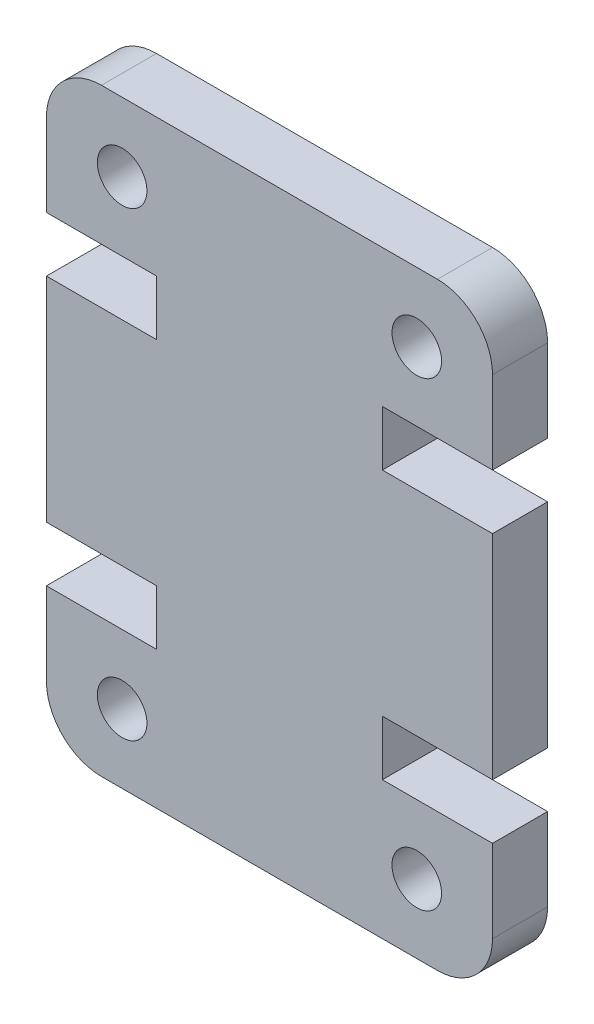
from build123d import *

# Parameters (mm, degrees)
SKETCH1_R           = 0.9
BOSS_EXTRUDE1_DEPTH = 4
SKETCH2_W           = 16.2
SKETCH2_H           = 21.74
CUT_EXTRUDE1_DEPTH  = 2


with BuildPart() as part:
    # Sketch1 → Boss-Extrude1 (new body)
    with BuildSketch(Plane.XY):
        with BuildLine():
            Line((0, 14.74), (0, 7))
            Line((0, 7), (4, 7))
            Line((4, 7), (4, 5))
            Line((4, 5), (0, 5))
            Line((0, 5), (0, 2))
            ThreePointArc((0, 2), (0.585786438, 0.585786438), (2, 0))
            Line((2, 0), (14.2, 0))
            ThreePointArc((14.2, 0), (15.614213562, 0.585786438), (16.2, 2))
            Line((16.2, 2), (16.2, 5))
            Line((16.2, 5), (12.2, 5))
            Line((12.2, 5), (12.2, 7))
            Line((12.2, 7), (16.2, 7))
            Line((16.2, 7), (16.2, 14.74))
            Line((16.2, 14.74), (12.2, 14.74))
            Line((12.2, 14.74), (12.2, 16.74))
            Line((12.2, 16.74), (16.2, 16.74))
            Line((16.2, 16.74), (16.2, 19.74))
            ThreePointArc((16.2, 19.74), (15.614213562, 21.154213562), (14.2, 21.74))
            Line((14.2, 21.74), (2, 21.74))
            ThreePointArc((2, 21.74), (0.585786438, 21.154213562), (0, 19.74))
            Line((0, 19.74), (0, 16.74))
            Line((0, 16.74), (4, 16.74))
            Line((4, 16.74), (4, 14.74))
            Line((4, 14.74), (0, 14.74))
        make_face()
        with Locations((13.45, 2.5)):
            Circle(SKETCH1_R, mode=Mode.SUBTRACT)
        with Locations((2.75, 19.24)):
            Circle(SKETCH1_R, mode=Mode.SUBTRACT)
        with Locations((2.75, 2.5)):
            Circle(SKETCH1_R, mode=Mode.SUBTRACT)
        with Locations((13.45, 19.24)):
            Circle(SKETCH1_R, mode=Mode.SUBTRACT)
    extrude(amount=BOSS_EXTRUDE1_DEPTH)

    # Sketch2 → Cut-Extrude1 (cut)
    with BuildSketch(Plane(origin=(0, 0, 0), x_dir=(-1, 0, 0), z_dir=(0, 0, -1))):
        with Locations((-8.1, 10.87)):
            Rectangle(SKETCH2_W, SKETCH2_H)
    extrude(amount=-CUT_EXTRUDE1_DEPTH, mode=Mode.SUBTRACT)


solid = part.part
